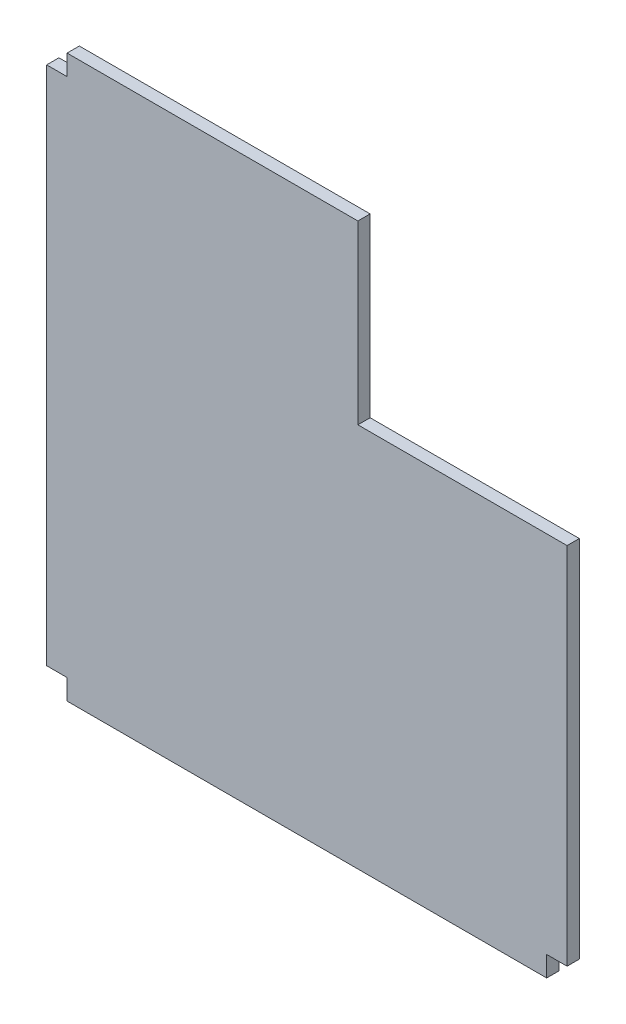
from build123d import *

# Parameters (mm, degrees)
SKETCH_1_W          = 470
SKETCH_1_H          = 510
SKETCH_1_H_2        = 20
SKETCH_1_W_2        = 20
EXTRUDE_1_DEPTH     = 12
SKETCH_2_W          = 185
SKETCH_2_H          = 153
SKETCH_2_W_2        = 20
SKETCH_2_H_2        = 20
CUT_EXTRUDE_1_DEPTH = 12


with BuildPart() as part:
    # ｽｹｯﾁ1 → ﾎﾞｽ - 押し出し1 (new body)
    with BuildSketch(Plane.XY):
        Rectangle(SKETCH_1_W, SKETCH_1_H)
        with Locations((0, 265)):
            Rectangle(SKETCH_1_W, SKETCH_1_H_2)
        with Locations((-245, 0)):
            Rectangle(SKETCH_1_W_2, SKETCH_1_H)
        with Locations((245, 0)):
            Rectangle(SKETCH_1_W_2, SKETCH_1_H)
        with Locations((0, -265)):
            Rectangle(SKETCH_1_W, SKETCH_1_H_2)
    extrude(amount=EXTRUDE_1_DEPTH)

    # ｽｹｯﾁ2 → ｶｯﾄ - 押し出し1 (cut)
    with BuildSketch(Plane(origin=(0, 0, 0), x_dir=(-1, 0, 0), z_dir=(0, 0, -1))):
        Polygon((-255, 255), (-235, 255), (-235, 275), (-50, 275), (-50, 308.587411224), (-364.697292758, 308.587411224), (-364.697292758, 102), (-255, 102), align=None)
        with Locations((-142.5, 178.5)):
            Rectangle(SKETCH_2_W, SKETCH_2_H)
        with Locations((-245, 178.5)):
            Rectangle(SKETCH_2_W_2, SKETCH_2_H)
        with Locations((-142.5, 265)):
            Rectangle(SKETCH_2_W, SKETCH_2_H_2)
    extrude(amount=-CUT_EXTRUDE_1_DEPTH, mode=Mode.SUBTRACT)


solid = part.part
